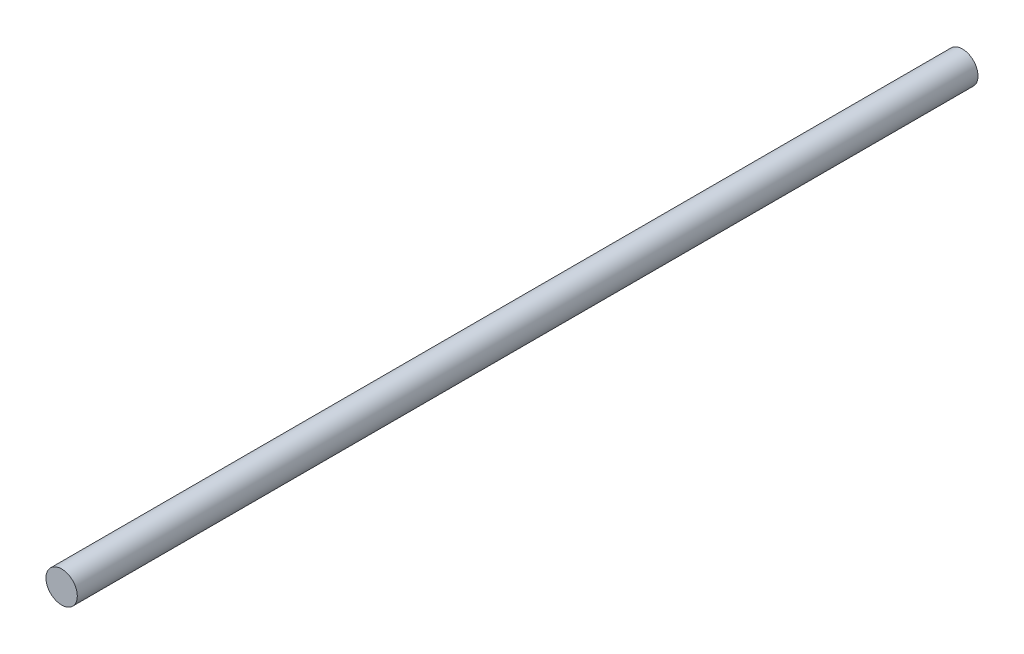
from build123d import *

# Parameters (mm, degrees)
SKETCH1_R           = 4
BOSS_EXTRUDE1_DEPTH = 230


with BuildPart() as part:
    # Sketch1 → Boss-Extrude1 (new body)
    with BuildSketch(Plane.XY):
        with Locations((-32.400371914, 2.118779079)):
            Circle(SKETCH1_R)
    extrude(amount=BOSS_EXTRUDE1_DEPTH)


solid = part.part
